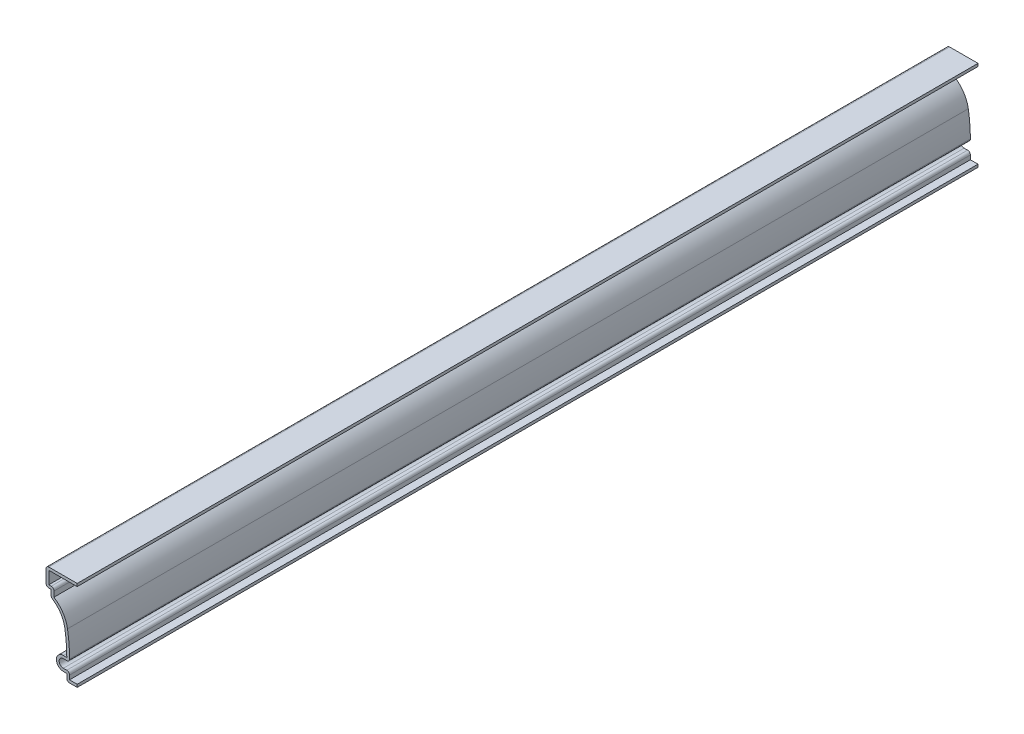
from build123d import *

# Parameters (mm, degrees)
EXTRUDE_THIN1_DEPTH = 412.75
FILLET1_R           = 1.27


with BuildPart() as part:
    # Sketch1 → Extrude-Thin1 (new body)
    with BuildSketch(Plane.XY):
        with BuildLine():
            Line((0, 41.275), (-14.2875, 41.275))
            Line((-14.2875, 41.275), (-14.2875, 32.940625))
            Line((-14.2875, 32.940625), (-11.90625, 32.940625))
            Line((-11.90625, 32.940625), (-11.90625, 29.765625))
            ThreePointArc((-11.90625, 29.765625), (-7.793372209, 25.995204752), (-5.693451363, 20.825856146))
            ThreePointArc((-5.693451363, 20.825856146), (-4.995631362, 15.194568327), (-4.7625, 9.525))
            Line((-4.7625, 9.525), (-6.35, 9.525))
            ThreePointArc((-6.35, 9.525), (-9.525, 6.35), (-6.35, 3.175))
            Line((-6.35, 3.175), (-4.7625, 3.175))
            Line((-4.7625, 3.175), (-4.7625, 0))
            Line((-4.7625, 0), (0, 0))
            Line((0, 0), (0, 1.27))
            Line((0, 1.27), (-3.4925, 1.27))
            Line((-3.4925, 1.27), (-3.4925, 4.445))
            Line((-3.4925, 4.445), (-6.35, 4.445))
            ThreePointArc((-6.35, 4.445), (-8.255, 6.35), (-6.35, 8.255))
            Line((-6.35, 8.255), (-3.503968204, 8.255))
            ThreePointArc((-3.503968204, 8.255), (-3.680640178, 14.665718794), (-4.440572307, 21.033687983))
            ThreePointArc((-4.440572307, 21.033687983), (-6.541275078, 26.410168765), (-10.63625, 30.47842123))
            Line((-10.63625, 30.47842123), (-10.63625, 34.210625))
            Line((-10.63625, 34.210625), (-13.0175, 34.210625))
            Line((-13.0175, 34.210625), (-13.0175, 40.005))
            Line((-13.0175, 40.005), (0, 40.005))
            Line((0, 40.005), (0, 41.275))
        make_face()
    extrude(amount=-EXTRUDE_THIN1_DEPTH)

    # Fillet1
    fillet1_edges = [part.edges().sort_by_distance(p)[0] for p in [
        (-4.7625, 0, -206.375),
        (-11.90625, 29.765625, -206.375),
        (-14.2875, 32.940625, -206.375),
        (-14.2875, 41.275, -206.375),
        (-10.63625, 34.210625, -206.375),
        (-3.503968204, 8.255, -206.375),
        (-3.4925, 4.445, -206.375),
    ]]
    fillet(fillet1_edges, radius=FILLET1_R)


solid = part.part
